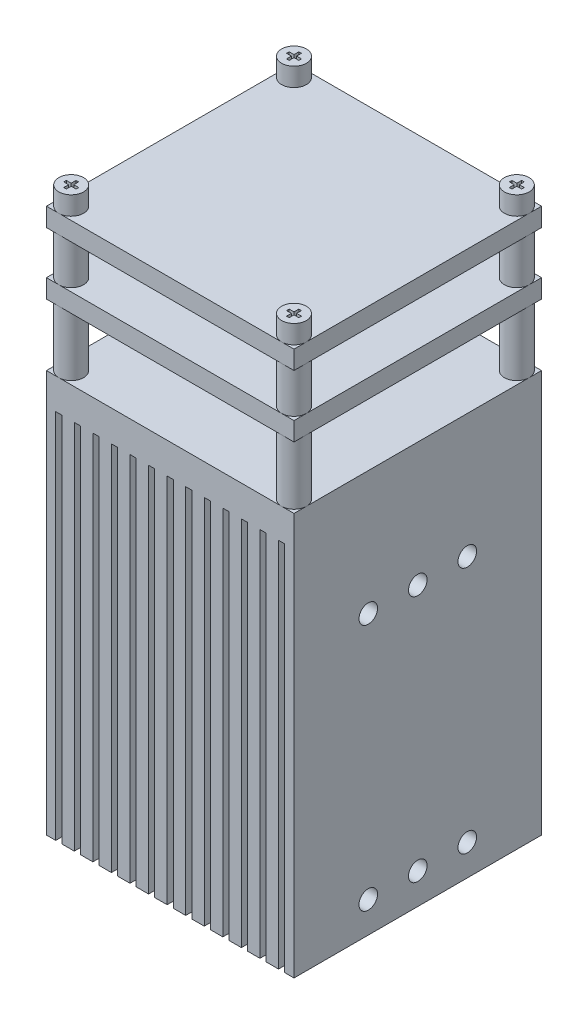
from build123d import *

# Parameters (mm, degrees)
SKETCH1_W           = 40
SKETCH1_H           = 40
BOSS_EXTRUDE1_DEPTH = 65
SKETCH2_R           = 7
SKETCH2_R_2         = 2
BOSS_EXTRUDE2_DEPTH = 10
SKETCH3_R           = 1.5
CUT_EXTRUDE1_DEPTH  = 10
SKETCH4_R           = 2
BOSS_EXTRUDE3_DEPTH = 10
SKETCH5_W           = 40
SKETCH5_H           = 40
BOSS_EXTRUDE4_DEPTH = 3
LPATTERN1_COUNT     = 2
LPATTERN1_PITCH     = 10
SKETCH6_R           = 2
BOSS_EXTRUDE5_DEPTH = 3
SKETCH7_W           = 1
SKETCH7_H           = 60
CUT_EXTRUDE2_DEPTH  = 1
SKETCH8_W           = 1
SKETCH8_H           = 60
CUT_EXTRUDE3_DEPTH  = 1


with BuildPart() as part:
    # Sketch1 → Boss-Extrude1 (new body)
    with BuildSketch(Plane(origin=(0, 0, 0), x_dir=(1, 0, 0), z_dir=(0, 1, 0))):
        Rectangle(SKETCH1_W, SKETCH1_H)
    extrude(amount=BOSS_EXTRUDE1_DEPTH)

    # Sketch2 → Boss-Extrude2 (add)
    with BuildSketch(Plane(origin=(0, 0, 0), x_dir=(-1, 0, 0), z_dir=(0, -1, 0))):
        Circle(SKETCH2_R)
        Circle(SKETCH2_R_2, mode=Mode.SUBTRACT)
    extrude(amount=BOSS_EXTRUDE2_DEPTH)

    # Sketch3 → Cut-Extrude1 (cut)
    with BuildSketch(Plane(origin=(20, 0, 0), x_dir=(0, 0, -1), z_dir=(1, 0, 0))):
        with Locations((0, 45)):
            Circle(SKETCH3_R)
        with Locations((-8, 45)):
            Circle(SKETCH3_R)
        with Locations((8, 45)):
            Circle(SKETCH3_R)
        with Locations((8, 5)):
            Circle(SKETCH3_R)
        with Locations((0, 5)):
            Circle(SKETCH3_R)
        with Locations((-8, 5)):
            Circle(SKETCH3_R)
    extrude(amount=-CUT_EXTRUDE1_DEPTH, mode=Mode.SUBTRACT)

    # Sketch4 → Boss-Extrude3 (add)
    with BuildSketch(Plane(origin=(0, 65, 0), x_dir=(1, 0, 0), z_dir=(0, 1, 0))):
        with Locations((18, -18)):
            Circle(SKETCH4_R)
        with Locations((-18, -18)):
            Circle(SKETCH4_R)
        with Locations((-18, 18)):
            Circle(SKETCH4_R)
        with Locations((18, 18)):
            Circle(SKETCH4_R)
    boss_extrude3 = extrude(amount=BOSS_EXTRUDE3_DEPTH)

    # Sketch5 → Boss-Extrude4 (add)
    with BuildSketch(Plane(origin=(0, 75, 0), x_dir=(1, 0, 0), z_dir=(0, 1, 0))):
        Rectangle(SKETCH5_W, SKETCH5_H)
    boss_extrude4 = extrude(amount=BOSS_EXTRUDE4_DEPTH)

    # LPattern1: Boss-Extrude3, Boss-Extrude4 ×2
    with Locations(*[(0, i * LPATTERN1_PITCH, 0) for i in range(1, LPATTERN1_COUNT)]):
        add(boss_extrude3)
        add(boss_extrude4)

    # Sketch6 → Boss-Extrude5 (add)
    with BuildSketch(Plane(origin=(0, 88, 0), x_dir=(1, 0, 0), z_dir=(0, 1, 0))):
        with Locations((18, -18)):
            Circle(SKETCH6_R)
        Polygon((17.787513471, -17.003358482), (18.212486529, -17.003358482), (18.212486529, -17.787513471), (18.996641518, -17.787513471), (18.996641518, -18.212486529), (18.212486529, -18.212486529), (18.212486529, -18.996641518), (17.787513471, -18.996641518), (17.787513471, -18.212486529), (17.003358482, -18.212486529), (17.003358482, -17.787513471), (17.787513471, -17.787513471), align=None, mode=Mode.SUBTRACT)
        with Locations((-18, -18)):
            Circle(SKETCH6_R)
        Polygon((-17.787513471, -18.996641518), (-17.787513471, -18.212486529), (-17.003358482, -18.212486529), (-17.003358482, -17.787513471), (-17.787513471, -17.787513471), (-17.787513471, -17.003358482), (-18.212486529, -17.003358482), (-18.212486529, -17.787513471), (-18.996641518, -17.787513471), (-18.996641518, -18.212486529), (-18.212486529, -18.212486529), (-18.212486529, -18.996641518), align=None, mode=Mode.SUBTRACT)
        with Locations((-18, 18)):
            Circle(SKETCH6_R)
        Polygon((-18.996641518, 17.787513471), (-18.212486529, 17.787513471), (-18.212486529, 17.003358482), (-17.787513471, 17.003358482), (-17.787513471, 17.787513471), (-17.003358482, 17.787513471), (-17.003358482, 18.212486529), (-17.787513471, 18.212486529), (-17.787513471, 18.996641518), (-18.212486529, 18.996641518), (-18.212486529, 18.212486529), (-18.996641518, 18.212486529), align=None, mode=Mode.SUBTRACT)
        with Locations((18, 18)):
            Circle(SKETCH6_R)
        Polygon((17.787513471, 18.996641518), (17.787513471, 18.212486529), (17.003358482, 18.212486529), (17.003358482, 17.787513471), (17.787513471, 17.787513471), (17.787513471, 17.003358482), (18.212486529, 17.003358482), (18.212486529, 17.787513471), (18.996641518, 17.787513471), (18.996641518, 18.212486529), (18.212486529, 18.212486529), (18.212486529, 18.996641518), align=None, mode=Mode.SUBTRACT)
    extrude(amount=BOSS_EXTRUDE5_DEPTH)

    # Sketch7 → Cut-Extrude2 (cut)
    with BuildSketch(Plane.ZY.offset(20)):
        with Locations((0, 30)):
            Rectangle(SKETCH7_W, SKETCH7_H)
        with Locations((3, 30)):
            Rectangle(SKETCH7_W, SKETCH7_H)
        with Locations((6, 30)):
            Rectangle(SKETCH7_W, SKETCH7_H)
        with Locations((9, 30)):
            Rectangle(SKETCH7_W, SKETCH7_H)
        with Locations((12, 30)):
            Rectangle(SKETCH7_W, SKETCH7_H)
        with Locations((15, 30)):
            Rectangle(SKETCH7_W, SKETCH7_H)
        with Locations((18, 30)):
            Rectangle(SKETCH7_W, SKETCH7_H)
        with Locations((-3, 30)):
            Rectangle(SKETCH7_W, SKETCH7_H)
        with Locations((-6, 30)):
            Rectangle(SKETCH7_W, SKETCH7_H)
        with Locations((-9, 30)):
            Rectangle(SKETCH7_W, SKETCH7_H)
        with Locations((-12, 30)):
            Rectangle(SKETCH7_W, SKETCH7_H)
        with Locations((-15, 30)):
            Rectangle(SKETCH7_W, SKETCH7_H)
        with Locations((-18, 30)):
            Rectangle(SKETCH7_W, SKETCH7_H)
    extrude(amount=-CUT_EXTRUDE2_DEPTH, mode=Mode.SUBTRACT)

    # Sketch8 → Cut-Extrude3 (cut)
    with BuildSketch(Plane(origin=(0, 0, -20), x_dir=(-1, 0, 0), z_dir=(0, 0, -1))):
        with Locations((0, 30)):
            Rectangle(SKETCH8_W, SKETCH8_H)
        with Locations((3, 30)):
            Rectangle(SKETCH8_W, SKETCH8_H)
        with Locations((6, 30)):
            Rectangle(SKETCH8_W, SKETCH8_H)
        with Locations((9, 30)):
            Rectangle(SKETCH8_W, SKETCH8_H)
        with Locations((12, 30)):
            Rectangle(SKETCH8_W, SKETCH8_H)
        with Locations((15, 30)):
            Rectangle(SKETCH8_W, SKETCH8_H)
        with Locations((18, 30)):
            Rectangle(SKETCH8_W, SKETCH8_H)
        with Locations((-3, 30)):
            Rectangle(SKETCH8_W, SKETCH8_H)
        with Locations((-6, 30)):
            Rectangle(SKETCH8_W, SKETCH8_H)
        with Locations((-9, 30)):
            Rectangle(SKETCH8_W, SKETCH8_H)
        with Locations((-12, 30)):
            Rectangle(SKETCH8_W, SKETCH8_H)
        with Locations((-15, 30)):
            Rectangle(SKETCH8_W, SKETCH8_H)
        with Locations((-18, 30)):
            Rectangle(SKETCH8_W, SKETCH8_H)
    cut_extrude3 = extrude(amount=-CUT_EXTRUDE3_DEPTH, mode=Mode.SUBTRACT)

    # Mirror1: Cut-Extrude3 across plane
    add(cut_extrude3.mirror(Plane.XY), mode=Mode.SUBTRACT)


solid = part.part
